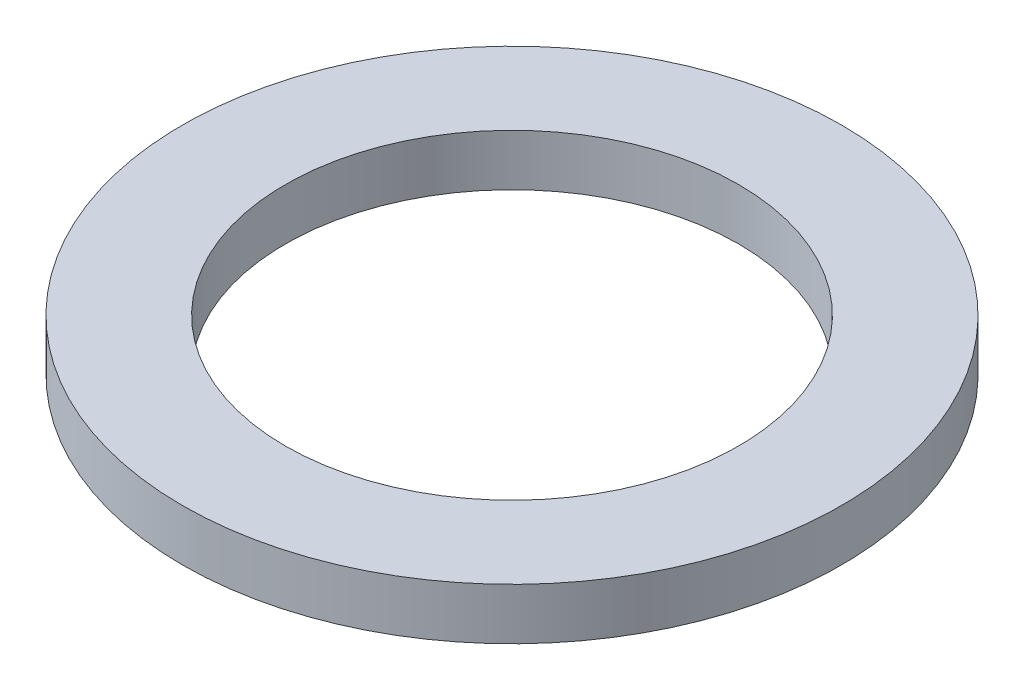
from build123d import *

# Parameters (mm, degrees)
ESQUISSE1_R        = 1.6
ESQUISSE1_R_2      = 1.1
BOSS_EXTRU_1_DEPTH = 0.25


with BuildPart() as part:
    # Esquisse1 → Boss.-Extru.1 (new body)
    with BuildSketch(Plane(origin=(0, 0, 0), x_dir=(1, 0, 0), z_dir=(0, 1, 0))):
        with Locations(Location((0, 0, 0), (0, 0, 270))):  # turned: the seam where the file's is
            Circle(ESQUISSE1_R)
        with Locations(Location((0, 0, 0), (0, 0, 270))):  # turned: the seam where the file's is
            Circle(ESQUISSE1_R_2, mode=Mode.SUBTRACT)
    extrude(amount=BOSS_EXTRU_1_DEPTH)


solid = part.part
